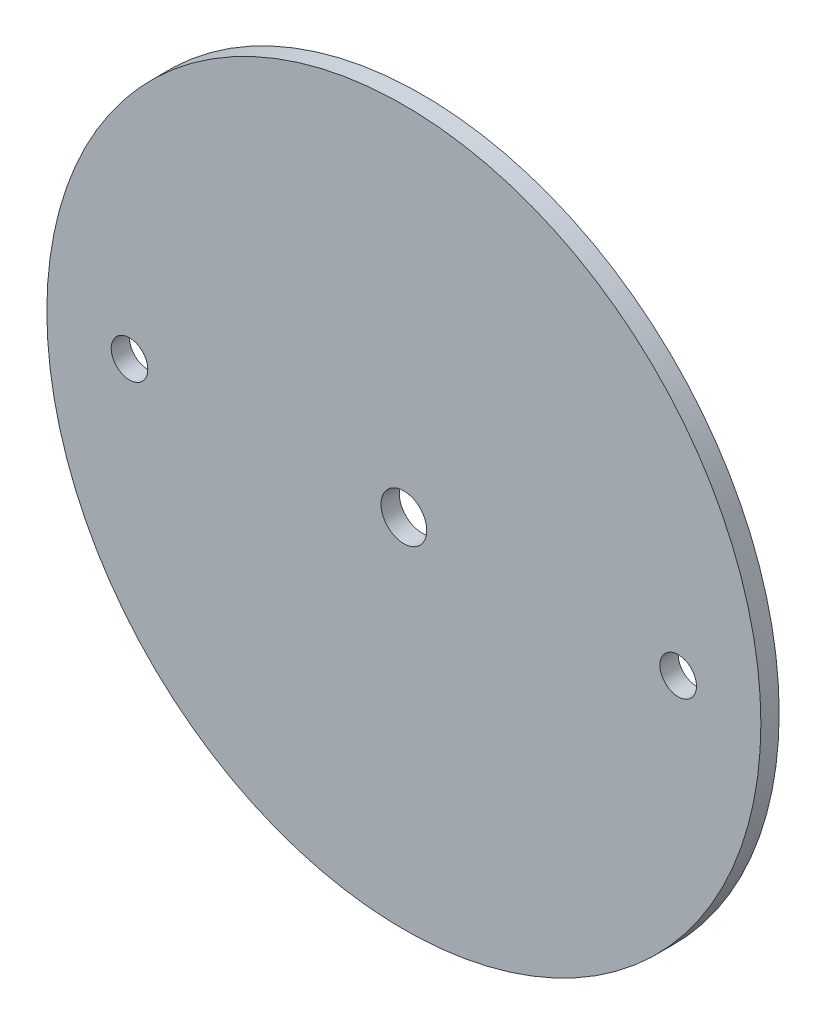
from build123d import *

# Parameters (mm, degrees)
SKETCH1_R                          = 61.976
BOSS_EXTRUDE1_DEPTH                = 1.5875
F_1_4_0_25_DIAMETER_HOLE1_D        = 6.35
F_5_16_0_3125_DIAMETER_HOLE1_D     = 7.9375
F_5_16_0_3125_DIAMETER_HOLE1_DEPTH = 3.302


with BuildPart() as part:
    # Sketch1 → Boss-Extrude1 (new body, symmetric)
    with BuildSketch(Plane.XY):
        Circle(SKETCH1_R)
    extrude(amount=BOSS_EXTRUDE1_DEPTH, both=True)

    # 1/4 (0.25) Diameter Hole1 (through all)
    with Locations(Plane.XY.offset(1.5875)):
        with Locations((-47.625, 0), (47.625, 0)):
            Hole(F_1_4_0_25_DIAMETER_HOLE1_D / 2)

    # 5/16 (0.3125) Diameter Hole1
    with Locations(Plane.XY.offset(1.5875)):
        with Locations((0, 0)):
            Hole(F_5_16_0_3125_DIAMETER_HOLE1_D / 2, depth=F_5_16_0_3125_DIAMETER_HOLE1_DEPTH)


solid = part.part
